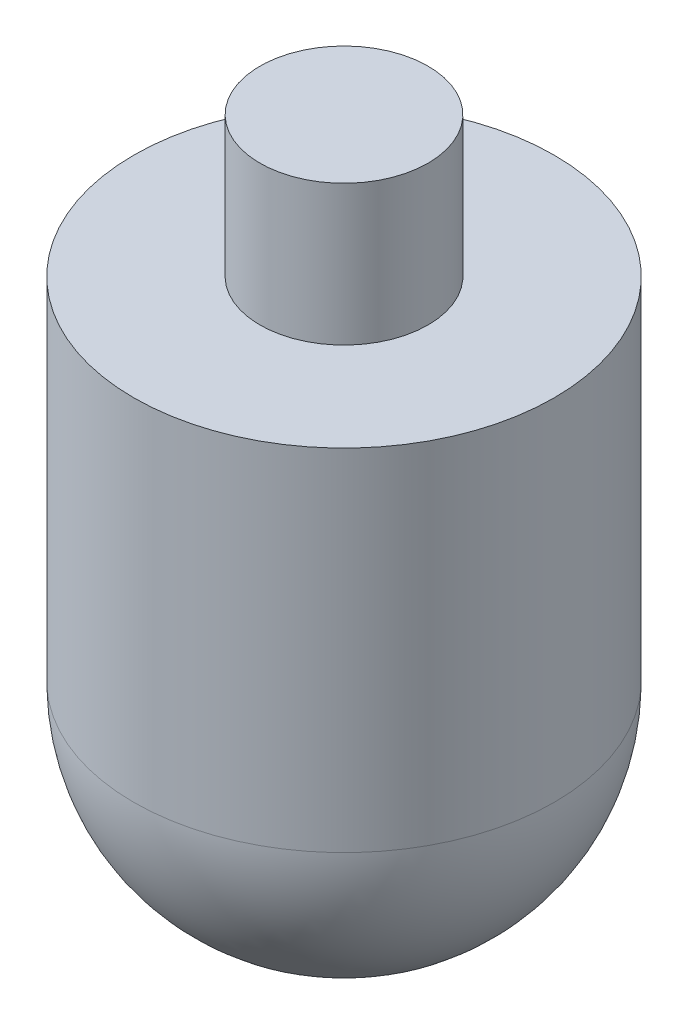
from build123d import *


with BuildPart() as part:
    # Sketch1 → Revolve2 (revolve)
    with BuildSketch(Plane.XY, mode=Mode.PRIVATE) as revolve2_sk:
        with BuildLine():
            Line((0, -15), (0, 0))
            Line((0, 0), (-15, 0))
            ThreePointArc((-15, 0), (-10.606601718, -10.606601718), (0, -15))
        make_face()
        Polygon((-15, 0), (0, 0), (0, 35), (-6, 35), (-6, 25), (-15, 25), align=None)
    revolve(revolve2_sk.sketch.rotate(Axis((0, -15, 0), (0, 1, 0)), 180), axis=Axis((0, -15, 0), (0, 1, 0)))  # turned: the seam where the file's is


solid = part.part
